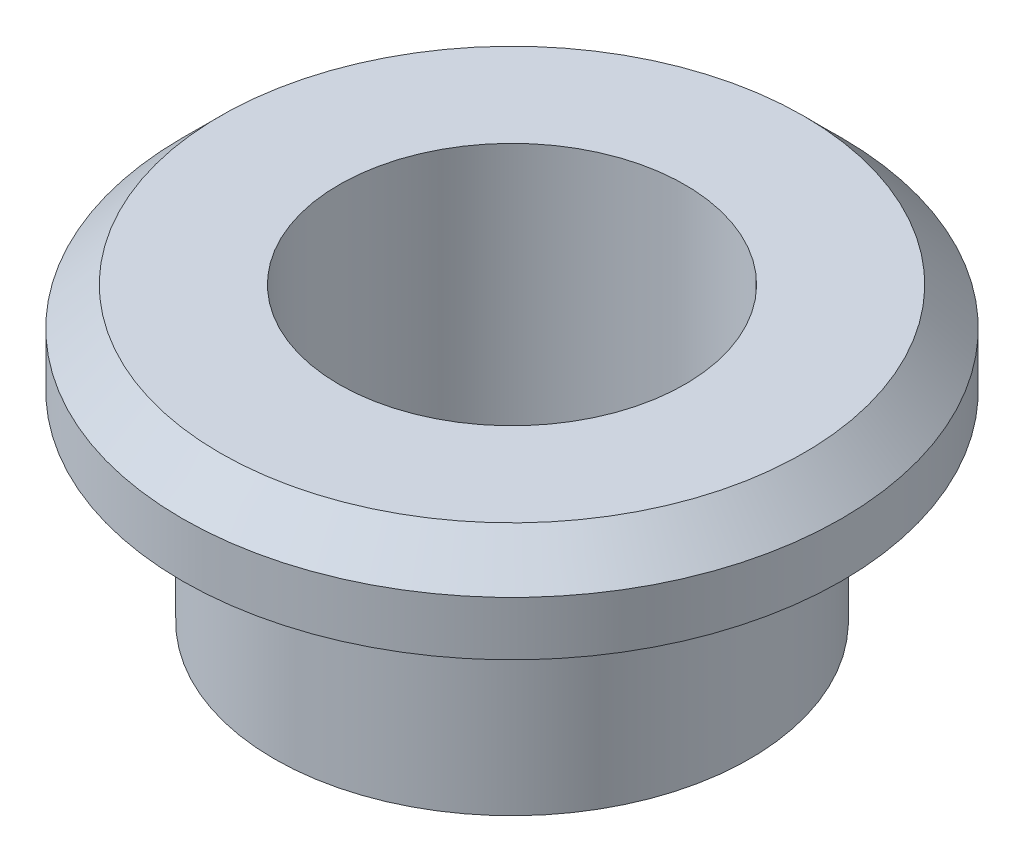
from build123d import *


with BuildPart() as part:
    # Sketch1 → Revolve1 (revolve)
    with BuildSketch(Plane.XY):
        Polygon((1.6, 2.7), (1.6, 0), (2.2, 0), (2.2, 1.85), (3.05, 1.85), (3.05, 2.35), (2.7, 2.7), align=None)
    revolve(axis=Axis((0, 9.791147956, 0), (0, -1, 0)))


solid = part.part
